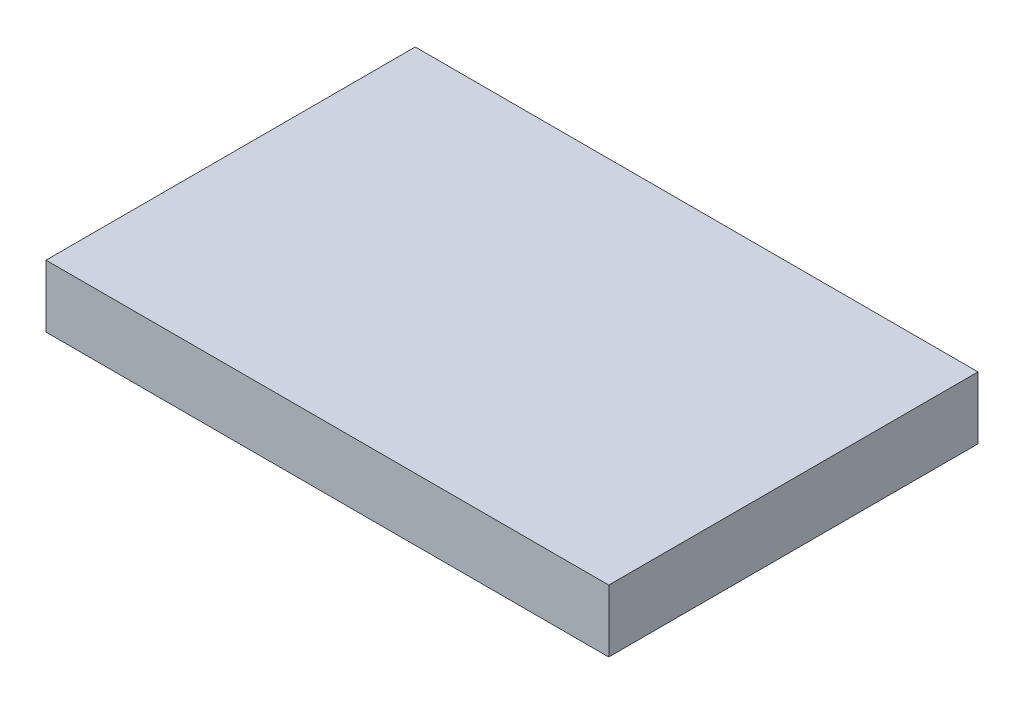
from build123d import *

# Parameters (mm, degrees)
SKETCH1_W           = 81.28
SKETCH1_H           = 53.33
BOSS_EXTRUDE1_DEPTH = 9


with BuildPart() as part:
    # Sketch1 → Boss-Extrude1 (new body)
    with BuildSketch(Plane(origin=(0, 0, 0), x_dir=(1, 0, 0), z_dir=(0, 1, 0))):
        Rectangle(SKETCH1_W, SKETCH1_H)
    extrude(amount=BOSS_EXTRUDE1_DEPTH)


solid = part.part
